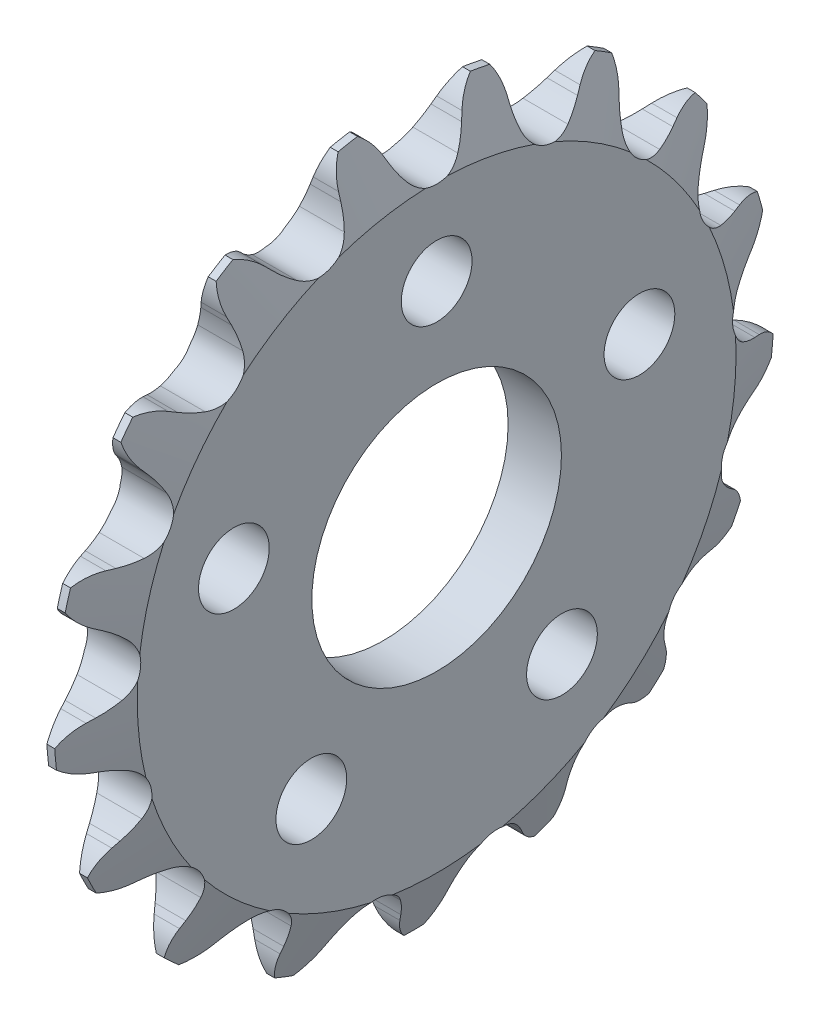
from build123d import *

# Parameters (mm, degrees)
CUT_EXTRUDE1_DEPTH = 27.717746938
CIRPATTERN1_COUNT  = 17
SKETCH4_R          = 6.5405
SKETCH4_R_2        = 1.8542
CUT_EXTRUDE2_DEPTH = 27.799125112


with BuildPart() as part:
    # Sketch2 → Revolve1 (revolve)
    with BuildSketch(Plane.XY):
        Polygon((-0.206375, 18.866456907), (0.206375, 18.866456907), (1.397, 15.691456907), (1.397, 0), (-1.397, 0), (-1.397, 15.691456907), align=None)
    revolve(axis=Axis((-1.397, 0, 0), (1, 0, 0)))

    # Sketch3 → Cut-Extrude1 (cut, symmetric)
    with BuildSketch(Plane(origin=(0, 0, 0), x_dir=(0, 0, -1), z_dir=(1, 0, 0))):
        with BuildLine():
            Line((-2.059398032, 17.526617596), (-1.902756136, 17.171857521))
            ThreePointArc((-1.902756136, 17.171857521), (-1.645816478, 16.678281032), (-1.327821292, 16.221646823))
            ThreePointArc((-1.327821292, 16.221646823), (0, 15.581601907), (1.327821292, 16.221646823))
            ThreePointArc((1.327821292, 16.221646823), (1.645816478, 16.678281032), (1.902756136, 17.171857521))
            Line((1.902756136, 17.171857521), (2.059398032, 17.526617596))
            ThreePointArc((2.059398032, 17.526617596), (2.660737267, 18.386634411), (3.543211158, 18.954505547))
            ThreePointArc((3.543211158, 18.954505547), (0, 19.282832413), (-3.543211158, 18.954505547))
            ThreePointArc((-3.543211158, 18.954505547), (-2.660737267, 18.386634411), (-2.059398032, 17.526617596))
        make_face()
    cut_extrude1 = extrude(amount=CUT_EXTRUDE1_DEPTH, both=True, mode=Mode.SUBTRACT)

    # CirPattern1: Cut-Extrude1 ×17 about axis
    cirpattern1_axis = Axis((-88.99, 0, 0), (1, 0, 0))
    for i in range(1, CIRPATTERN1_COUNT):
        add(cut_extrude1.rotate(cirpattern1_axis, i * 360 / CIRPATTERN1_COUNT), mode=Mode.SUBTRACT)

    # Sketch4 → Cut-Extrude2 (cut, through all)
    with BuildSketch(Plane(origin=(1.397, 0, 0), x_dir=(0, 0, -1), z_dir=(1, 0, 0))):
        Circle(SKETCH4_R)
        with Locations((0, 11.176)):
            Circle(SKETCH4_R_2)
        with Locations((10.629007626, 3.453573929)):
            Circle(SKETCH4_R_2)
        with Locations((6.56908798, -9.041573929)):
            Circle(SKETCH4_R_2)
        with Locations((-6.56908798, -9.041573929)):
            Circle(SKETCH4_R_2)
        with Locations((-10.629007626, 3.453573929)):
            Circle(SKETCH4_R_2)
    extrude(amount=-CUT_EXTRUDE2_DEPTH, mode=Mode.SUBTRACT)


solid = part.part
